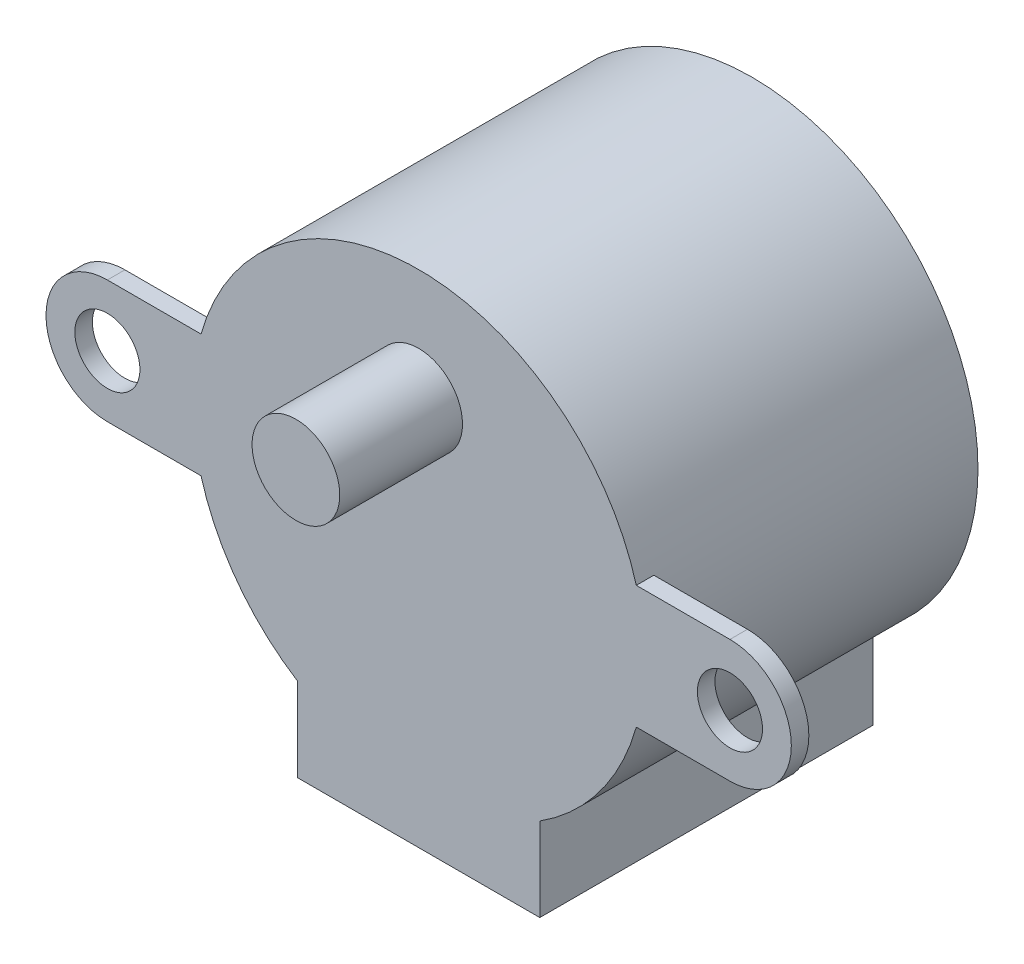
from build123d import *

# Parameters (mm, degrees)
ESBO_O1_R                = 1.85525586
RESSALTO_EXTRUS_O1_DEPTH = 19
CORTE_EXTRUS_O1_DEPTH    = 18
ESBO_O3_R                = 2.5
RESSALTO_EXTRUS_O2_DEPTH = 7


with BuildPart() as part:
    # Esboço1 → Ressalto-extrusão1 (new body)
    with BuildSketch(Plane.XY):
        with BuildLine():
            Line((17.75, 3.5), (12.410650194, 3.5))
            ThreePointArc((12.410650194, 3.5), (0, 12.894736842), (-12.410650194, 3.5))
            Line((-12.410650194, 3.5), (-17.75, 3.5))
            ThreePointArc((-17.75, 3.5), (-21.25, 0), (-17.75, -3.5))
            Line((-17.75, -3.5), (-12.410650194, -3.5))
            ThreePointArc((-12.410650194, -3.5), (-10.341581818, -7.702332356), (-6.907894737, -10.888306964))
            Line((-6.907894737, -10.888306964), (-6.907894737, -12.894736842))
            Line((-6.907894737, -12.894736842), (-6.907894737, -15.657894737))
            Line((-6.907894737, -15.657894737), (6.907894737, -15.657894737))
            Line((6.907894737, -15.657894737), (6.907894737, -12.894736842))
            Line((6.907894737, -12.894736842), (6.907894737, -10.888306964))
            ThreePointArc((6.907894737, -10.888306964), (10.341581818, -7.702332356), (12.410650194, -3.5))
            Line((12.410650194, -3.5), (17.75, -3.5))
            ThreePointArc((17.75, -3.5), (21.25, 0), (17.75, 3.5))
        make_face()
        with Locations((17.75, 0)):
            Circle(ESBO_O1_R, mode=Mode.SUBTRACT)
        with Locations((-17.75, 0)):
            Circle(ESBO_O1_R, mode=Mode.SUBTRACT)
    extrude(amount=RESSALTO_EXTRUS_O1_DEPTH)

    # Esboço2 → Corte-extrusão1 (cut)
    with BuildSketch(Plane(origin=(0, 0, 0), x_dir=(-1, 0, 0), z_dir=(0, 0, -1))):
        with BuildLine():
            Line((12.410650194, 3.5), (23.80699558, 3.5))
            Line((23.80699558, 3.5), (23.80699558, -3.5))
            Line((23.80699558, -3.5), (12.410650194, -3.5))
            ThreePointArc((12.410650194, -3.5), (12.894736842, 0), (12.410650194, 3.5))
        make_face()
        with BuildLine():
            Line((-12.410650194, 3.5), (-24.760546325, 3.5))
            Line((-24.760546325, 3.5), (-24.760546325, -3.5))
            Line((-24.760546325, -3.5), (-12.410650194, -3.5))
            ThreePointArc((-12.410650194, -3.5), (-12.894736842, 0), (-12.410650194, 3.5))
        make_face()
    extrude(amount=-CORTE_EXTRUS_O1_DEPTH, mode=Mode.SUBTRACT)

    # Esboço3 → Ressalto-extrusão2 (add)
    with BuildSketch(Plane.XY.offset(19)):
        with Locations((0, 6.5)):
            Circle(ESBO_O3_R)
    extrude(amount=RESSALTO_EXTRUS_O2_DEPTH)


solid = part.part
